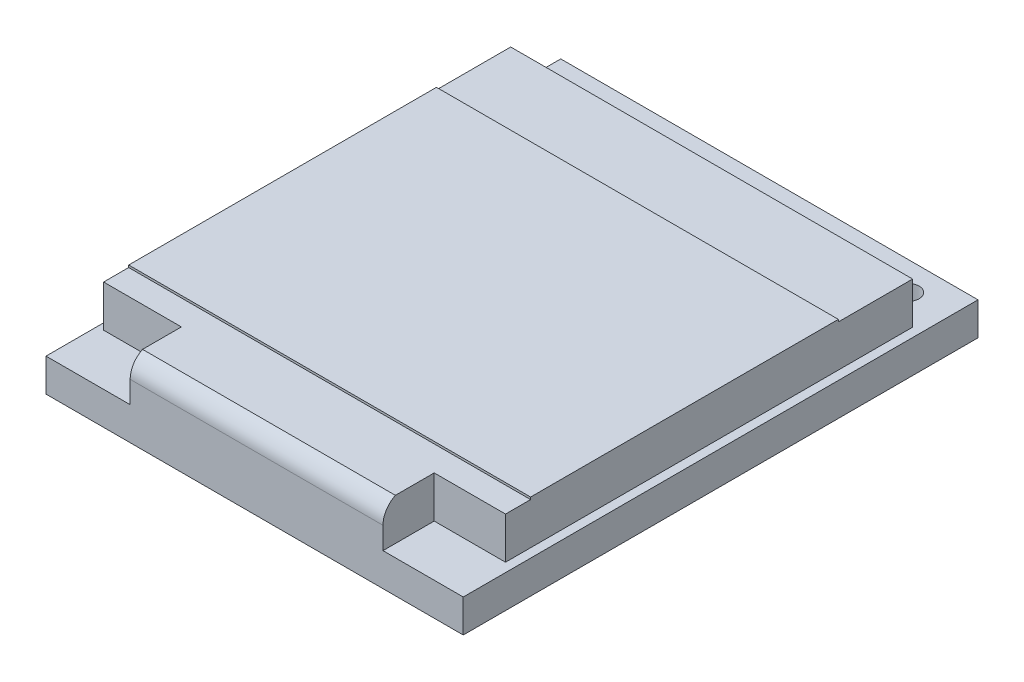
from build123d import *

# Parameters (mm, degrees)
SKETCH1_W           = 19
SKETCH1_H           = 23.44
SKETCH1_R           = 0.5
BOSS_EXTRUDE1_DEPTH = 1.5
BOSS_EXTRUDE2_DEPTH = 2
FILLET1_R           = 1
SKETCH4_W           = 18.301670477
SKETCH4_H           = 3.380629264
SKETCH4_H_2         = 3.475508354
CUT_EXTRUDE1_DEPTH  = 0.1


with BuildPart() as part:
    # Sketch1 → Boss-Extrude1 (new body)
    with BuildSketch(Plane(origin=(0, 0, 0), x_dir=(1, 0, 0), z_dir=(0, 1, 0))):
        with Locations((9.5, -11.72)):
            Rectangle(SKETCH1_W, SKETCH1_H)
        with Locations((1.88, -1.3)):
            Circle(SKETCH1_R, mode=Mode.SUBTRACT)
        with Locations((4.42, -1.3)):
            Circle(SKETCH1_R, mode=Mode.SUBTRACT)
        with Locations((6.96, -1.3)):
            Circle(SKETCH1_R, mode=Mode.SUBTRACT)
        with Locations((9.5, -1.3)):
            Circle(SKETCH1_R, mode=Mode.SUBTRACT)
        with Locations((12.04, -1.3)):
            Circle(SKETCH1_R, mode=Mode.SUBTRACT)
        with Locations((14.58, -1.3)):
            Circle(SKETCH1_R, mode=Mode.SUBTRACT)
        with Locations((17.12, -1.3)):
            Circle(SKETCH1_R, mode=Mode.SUBTRACT)
    extrude(amount=BOSS_EXTRUDE1_DEPTH)

    # Sketch3 → Boss-Extrude2 (add)
    with BuildSketch(Plane(origin=(0, 1.5, 0), x_dir=(1, 0, 0), z_dir=(0, 1, 0))):
        Polygon((3.832385917, -21.106985825), (3.832385917, -23.44), (15.344727023, -23.44), (15.344727023, -21.106985825), (18.591797592, -21.106985825), (18.591797592, -2.569164761), (0.290127115, -2.569164761), (0.290127115, -21.106985825), align=None)
    extrude(amount=BOSS_EXTRUDE2_DEPTH)

    # Fillet1
    fillet1_edges = [part.edges().sort_by_distance(p)[0] for p in [
        (9.58855647, 3.5, 23.44),
    ]]
    fillet(fillet1_edges, radius=FILLET1_R)

    # Sketch4 → Cut-Extrude1 (cut)
    with BuildSketch(Plane(origin=(0, 3.5, 0), x_dir=(1, 0, 0), z_dir=(0, 1, 0))):
        with Locations((9.440962354, -4.259479393)):
            Rectangle(SKETCH4_W, SKETCH4_H)
        with Locations((9.440962354, -21.702245823)):
            Rectangle(SKETCH4_W, SKETCH4_H_2)
    extrude(amount=-CUT_EXTRUDE1_DEPTH, mode=Mode.SUBTRACT)


solid = part.part
